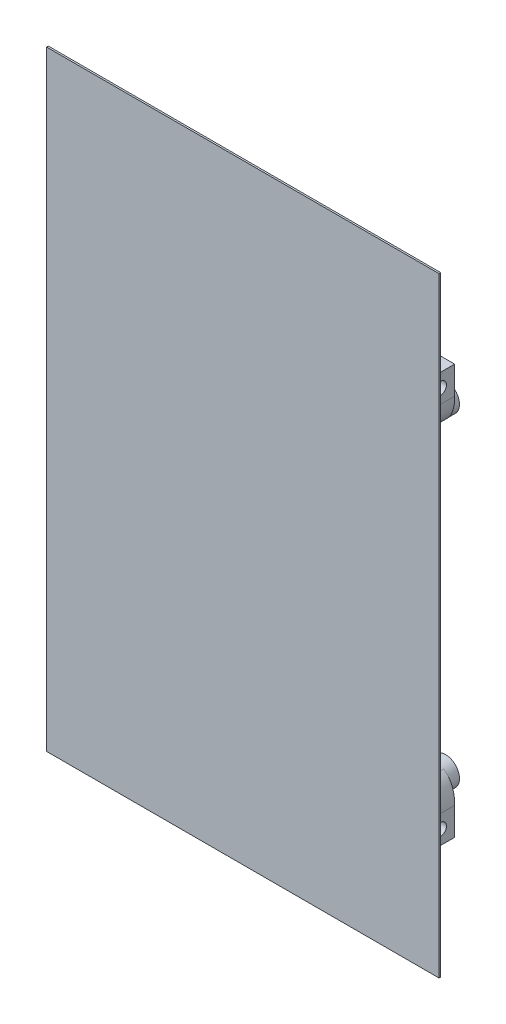
from build123d import *

# Parameters (mm, degrees)
SKETCH1_W               = 113
SKETCH1_H               = 175.618176042
BOSS_EXTRUDE1_DEPTH     = 0.5
SKETCH2_R               = 4
SKETCH2_R_2             = 2
BOSS_EXTRUDE2_DEPTH     = 11
CUT_EXTRUDE1_DEPTH      = 3
SKETCH4_W               = 5
SKETCH4_H               = 8
BOSS_EXTRUDE3_DEPTH     = 8
CUT_EXTRUDE2_REACH      = 194.244
SKETCH5_R               = 1.75
CUT_EXTRUDE3_DEPTH      = 2.5
MIRROR2_COPY_1_SKETCH_W = 5
MIRROR2_COPY_1_SKETCH_H = 8
MIRROR2_COPY_1_DEPTH    = 8
MIRROR2_COPY_2_REACH    = 194.244
MIRROR2_COPY_2_SKETCH_R = 1.75
MIRROR2_COPY_3_DEPTH    = 2.5


with BuildPart() as part:
    # Sketch1 → Boss-Extrude1 (new body)
    with BuildSketch(Plane.XY):
        with Locations((52.5, 73.5)):
            Rectangle(SKETCH1_W, SKETCH1_H)
    extrude(amount=BOSS_EXTRUDE1_DEPTH)

    # Sketch2 → Boss-Extrude2 (add)
    with BuildSketch(Plane(origin=(0, 0, 0), x_dir=(-1, 0, 0), z_dir=(0, 0, -1))):
        with Locations(Location((-5.6, 120.15, 0), (0, 0, 180))):
            Circle(SKETCH2_R)
        with Locations(Location((-5.6, 120.15, 0), (0, 0, 180))):
            Circle(SKETCH2_R_2, mode=Mode.SUBTRACT)
        with Locations(Location((-5.6, 26.85, 0), (0, 0, 180))):
            Circle(SKETCH2_R)
        with Locations(Location((-5.6, 26.85, 0), (0, 0, 180))):
            Circle(SKETCH2_R_2, mode=Mode.SUBTRACT)
        with Locations(Location((-99.4, 26.85, 0), (0, 0, 180))):
            Circle(SKETCH2_R)
        with Locations(Location((-99.4, 26.85, 0), (0, 0, 180))):
            Circle(SKETCH2_R_2, mode=Mode.SUBTRACT)
        with Locations(Location((-99.4, 120.15, 0), (0, 0, 180))):
            Circle(SKETCH2_R)
        with Locations(Location((-99.4, 120.15, 0), (0, 0, 180))):
            Circle(SKETCH2_R_2, mode=Mode.SUBTRACT)
    extrude(amount=BOSS_EXTRUDE2_DEPTH)

    # Sketch3 → Cut-Extrude1 (cut)
    with BuildSketch(Plane(origin=(0, 0, 0), x_dir=(-1, 0, 0), z_dir=(0, 0, -1))):
        Polygon((-101.132050808, 123.15), (-97.667949192, 123.15), (-95.935898385, 120.15), (-97.667949192, 117.15), (-101.132050808, 117.15), (-102.864101615, 120.15), align=None)
        with BuildLine():
            Line((-95.935898385, 120.15), (-97.667949192, 117.15))
            Line((-97.667949192, 117.15), (-96.754248689, 117.15))
            ThreePointArc((-96.754248689, 117.15), (-95.754248689, 118.504248689), (-95.4, 120.15))
            ThreePointArc((-95.4, 120.15), (-95.754248689, 121.795751311), (-96.754248689, 123.15))
            Line((-96.754248689, 123.15), (-97.667949192, 123.15))
            Line((-97.667949192, 123.15), (-95.935898385, 120.15))
        make_face()
        Polygon((-3.867949192, 123.15), (-7.332050808, 123.15), (-9.064101615, 120.15), (-7.332050808, 117.15), (-3.867949192, 117.15), (-2.135898385, 120.15), align=None)
        with BuildLine():
            Line((-9.064101615, 120.15), (-7.332050808, 123.15))
            Line((-7.332050808, 123.15), (-8.245751311, 123.15))
            ThreePointArc((-8.245751311, 123.15), (-9.6, 120.15), (-8.245751311, 117.15))
            Line((-8.245751311, 117.15), (-7.332050808, 117.15))
            Line((-7.332050808, 117.15), (-9.064101615, 120.15))
        make_face()
        Polygon((-3.867949192, 23.85), (-7.332050808, 23.85), (-9.064101615, 26.85), (-7.332050808, 29.85), (-3.867949192, 29.85), (-2.135898385, 26.85), align=None)
        with BuildLine():
            Line((-9.064101615, 26.85), (-7.332050808, 29.85))
            Line((-7.332050808, 29.85), (-8.245751311, 29.85))
            ThreePointArc((-8.245751311, 29.85), (-9.6, 26.85), (-8.245751311, 23.85))
            Line((-8.245751311, 23.85), (-7.332050808, 23.85))
            Line((-7.332050808, 23.85), (-9.064101615, 26.85))
        make_face()
        Polygon((-101.132050808, 23.85), (-97.667949192, 23.85), (-95.935898385, 26.85), (-97.667949192, 29.85), (-101.132050808, 29.85), (-102.864101615, 26.85), align=None)
        with BuildLine():
            Line((-95.935898385, 26.85), (-97.667949192, 23.85))
            Line((-97.667949192, 23.85), (-96.754248689, 23.85))
            ThreePointArc((-96.754248689, 23.85), (-95.754248689, 25.204248689), (-95.4, 26.85))
            ThreePointArc((-95.4, 26.85), (-95.754248689, 28.495751311), (-96.754248689, 29.85))
            Line((-96.754248689, 29.85), (-97.667949192, 29.85))
            Line((-97.667949192, 29.85), (-95.935898385, 26.85))
        make_face()
    extrude(amount=CUT_EXTRUDE1_DEPTH, mode=Mode.SUBTRACT)

    # Sketch4 → Boss-Extrude3 (add)
    with BuildSketch(Plane(origin=(0, 0, 0), x_dir=(-1, 0, 0), z_dir=(0, 0, -1))):
        with Locations((-102.5, 18.5)):
            Rectangle(SKETCH4_W, SKETCH4_H)
        with BuildLine():
            add(Edge.make_bspline(
                [(-105, 22.5), (-105, 25.54291505), (-104.360830865, 28.066908547), (-101.849562653, 30.012221183)],
                knots=[0, 0, 0, 0, 1, 1, 1, 1], degree=3))
            Line((-105, 22.5), (-100, 22.5))
            Line((-100, 22.5), (-100, 22.895256013))
            ThreePointArc((-100, 22.895256013), (-103.271402382, 25.843896824), (-101.849562653, 30.012221183))
        make_face()
    boss_extrude3 = extrude(amount=BOSS_EXTRUDE3_DEPTH)

    # Sketch5 → Cut-Extrude2 (cut, up to next)
    with BuildSketch(Plane.ZY.offset(-100), mode=Mode.PRIVATE) as cut_extrude2_sk1:
        with Locations((-3.896353455, 18.5)):
            Circle(SKETCH5_R)
    cut_extrude2_tool1 = extrude(cut_extrude2_sk1.sketch, amount=-CUT_EXTRUDE2_REACH, mode=Mode.PRIVATE) & part.part
    cut_extrude2 = cut_extrude2_tool1.solids().sort_by_distance((100, 18.5, -3.896353))[0]
    add(cut_extrude2, mode=Mode.SUBTRACT)

    # Sketch6 → Cut-Extrude3 (cut)
    with BuildSketch(Plane.ZY.offset(-100)):
        Polygon((-3.896353455, 21.964101615), (-6.896353455, 20.232050808), (-6.896353455, 16.767949192), (-3.896353455, 15.035898385), (-0.896353455, 16.767949192), (-0.896353455, 20.232050808), align=None)
    cut_extrude3 = extrude(amount=-CUT_EXTRUDE3_DEPTH, mode=Mode.SUBTRACT)

    # Mirror1: Boss-Extrude3, Cut-Extrude2, Cut-Extrude3 across plane
    add(boss_extrude3.mirror(Plane.ZY.offset(-52.5)))
    add(cut_extrude2.mirror(Plane.ZY.offset(-52.5)), mode=Mode.SUBTRACT)
    add(cut_extrude3.mirror(Plane.ZY.offset(-52.5)), mode=Mode.SUBTRACT)

    # Mirror2: Boss-Extrude3, Cut-Extrude2, Cut-Extrude3 across plane
    add(boss_extrude3.mirror(Plane(origin=(0, 73.5, 0), x_dir=(0, 0, 1), z_dir=(0, -1, 0))))
    add(cut_extrude2.mirror(Plane(origin=(0, 73.5, 0), x_dir=(0, 0, 1), z_dir=(0, -1, 0))), mode=Mode.SUBTRACT)
    add(cut_extrude3.mirror(Plane(origin=(0, 73.5, 0), x_dir=(0, 0, 1), z_dir=(0, -1, 0))), mode=Mode.SUBTRACT)

    # Mirror2 copy 1 sketch → Mirror2 copy 1 (add)
    with BuildSketch(Plane(origin=(105, 147, 0), x_dir=(1, 0, 0), z_dir=(0, 0, -1))):
        with Locations((-102.5, 18.5)):
            Rectangle(MIRROR2_COPY_1_SKETCH_W, MIRROR2_COPY_1_SKETCH_H)
        with BuildLine():
            add(Edge.make_bspline(
                [(-105, 22.5), (-105, 25.54291505), (-104.360830865, 28.066908547), (-101.849562653, 30.012221183)],
                knots=[0, 0, 0, 0, 1, 1, 1, 1], degree=3))
            Line((-105, 22.5), (-100, 22.5))
            Line((-100, 22.5), (-100, 22.895256013))
            ThreePointArc((-100, 22.895256013), (-103.271402382, 25.843896824), (-101.849562653, 30.012221183))
        make_face()
    extrude(amount=MIRROR2_COPY_1_DEPTH)

    # Mirror2 copy 2 sketch → Mirror2 copy 2 (cut, up to next)
    with BuildSketch(Plane(origin=(5, 147, 0), x_dir=(0, 0, 1), z_dir=(1, 0, 0)), mode=Mode.PRIVATE) as mirror2_copy_2_sk1:
        with Locations((-3.896353455, 18.5)):
            Circle(MIRROR2_COPY_2_SKETCH_R)
    mirror2_copy_2_tool1 = extrude(mirror2_copy_2_sk1.sketch, amount=-MIRROR2_COPY_2_REACH, mode=Mode.PRIVATE) & part.part
    add(mirror2_copy_2_tool1.solids().sort_by_distance((5, 128.5, -3.896353))[0], mode=Mode.SUBTRACT)

    # Mirror2 copy 3 sketch → Mirror2 copy 3 (cut)
    with BuildSketch(Plane(origin=(5, 147, 0), x_dir=(0, 0, 1), z_dir=(1, 0, 0))):
        Polygon((-3.896353455, 21.964101615), (-6.896353455, 20.232050808), (-6.896353455, 16.767949192), (-3.896353455, 15.035898385), (-0.896353455, 16.767949192), (-0.896353455, 20.232050808), align=None)
    extrude(amount=-MIRROR2_COPY_3_DEPTH, mode=Mode.SUBTRACT)


solid = part.part
